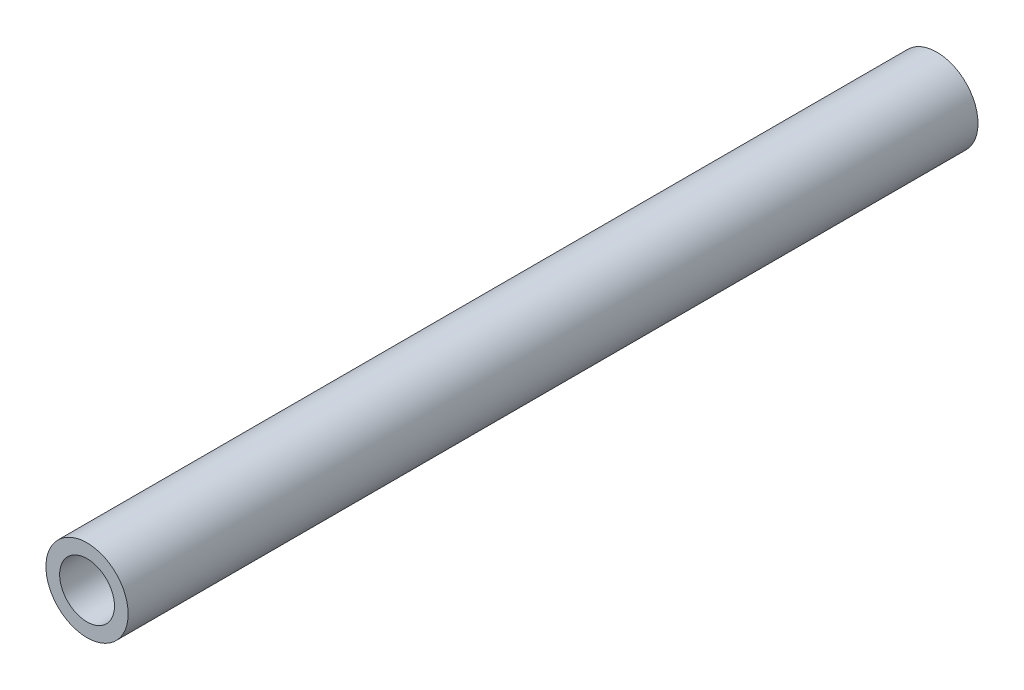
from build123d import *

# Parameters (mm, degrees)
SKETCH1_R           = 3
SKETCH1_R_2         = 2
BOSS_EXTRUDE1_DEPTH = 62


with BuildPart() as part:
    # Sketch1 → Boss-Extrude1 (new body)
    with BuildSketch(Plane.XY):
        Circle(SKETCH1_R)
        Circle(SKETCH1_R_2, mode=Mode.SUBTRACT)
    extrude(amount=BOSS_EXTRUDE1_DEPTH)


solid = part.part
